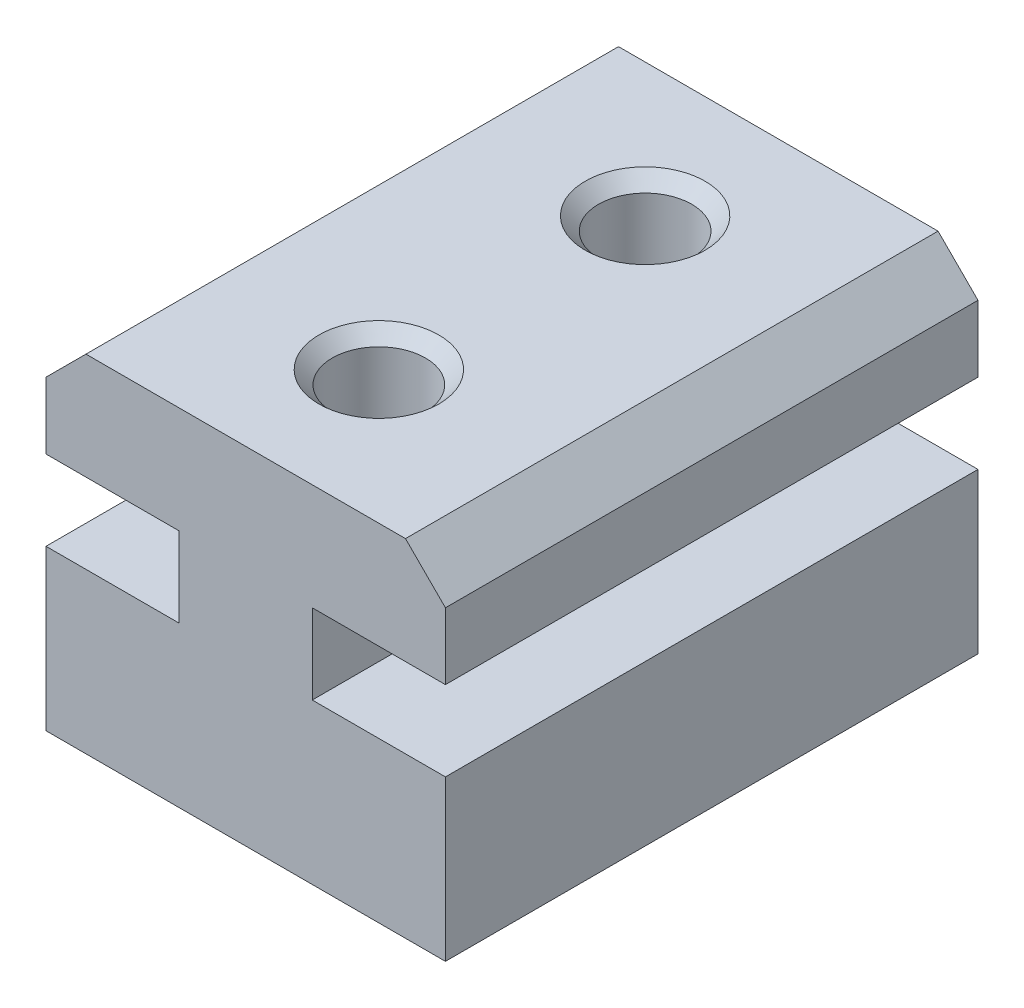
from build123d import *

# Parameters (mm, degrees)
BOSS_EXTRUDE1_DEPTH = 10
SKETCH2_R           = 1.75
CUT_EXTRUDE1_DEPTH  = 14
CHAMFER1_SIZE       = 1.5
CHAMFER3_SIZE       = 0.5


with BuildPart() as part:
    # Sketch1 → Boss-Extrude1 (new body, symmetric)
    with BuildSketch(Plane.XY):
        Polygon((0, 0), (15, 0), (15, 6), (10, 6), (10, 9), (15, 9), (15, 13), (0, 13), (0, 9), (5, 9), (5, 6), (0, 6), align=None)
    extrude(amount=BOSS_EXTRUDE1_DEPTH, both=True)

    # Sketch2 → Cut-Extrude1 (cut, through all)
    with BuildSketch(Plane(origin=(0, 13, 0), x_dir=(1, 0, 0), z_dir=(0, 1, 0))):
        with Locations((7.5, -5)):
            Circle(SKETCH2_R)
        with Locations((7.5, 5)):
            Circle(SKETCH2_R)
    extrude(amount=-CUT_EXTRUDE1_DEPTH, mode=Mode.SUBTRACT)

    # Chamfer1
    chamfer1_edges = [part.edges().sort_by_distance(p)[0] for p in [
        (0, 13, 0),
        (15, 13, 0),
    ]]
    chamfer(chamfer1_edges, length=CHAMFER1_SIZE)

    # Chamfer3
    chamfer3_edges = [part.edges().sort_by_distance(p)[0] for p in [
        (5.75, 13, 5),
        (5.75, 13, -5),
    ]]
    chamfer(chamfer3_edges, length=CHAMFER3_SIZE)


solid = part.part
